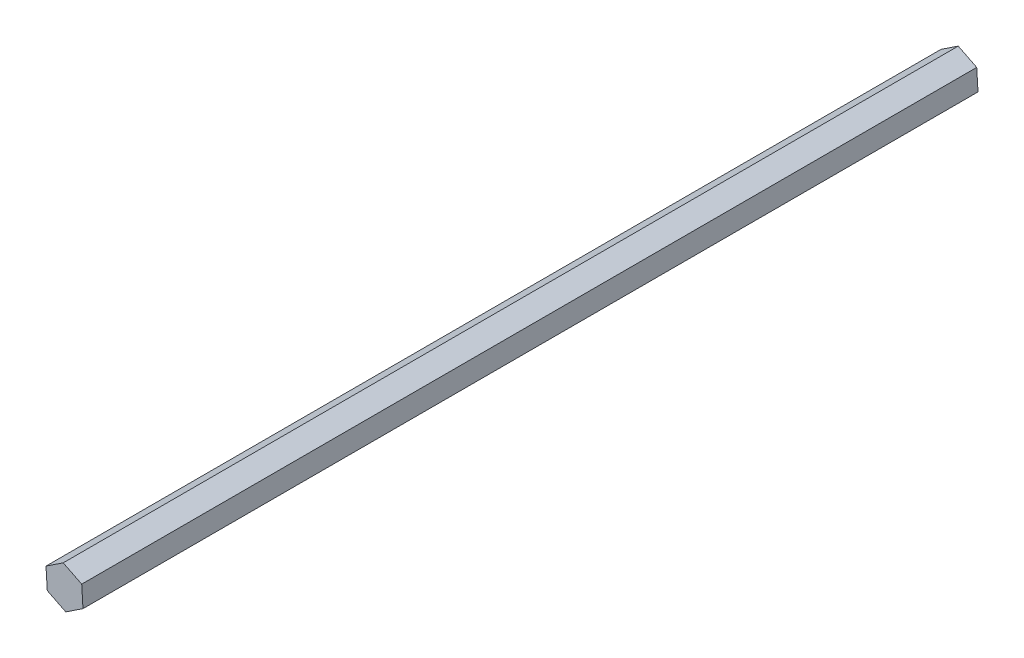
from build123d import *

# Parameters (mm, degrees)
BOSS_EXTRUDE1_DEPTH = 318.55


with BuildPart() as part:
    # Sketch1 → Boss-Extrude1 (new body)
    with BuildSketch(Plane.XY):
        Polygon((-0.45377191, 7.335979216), (-6.580030318, 3.275011606), (-6.126258407, -4.06096761), (0.45377191, -7.335979216), (6.580030318, -3.275011606), (6.126258407, 4.06096761), align=None)
    extrude(amount=BOSS_EXTRUDE1_DEPTH)


solid = part.part
